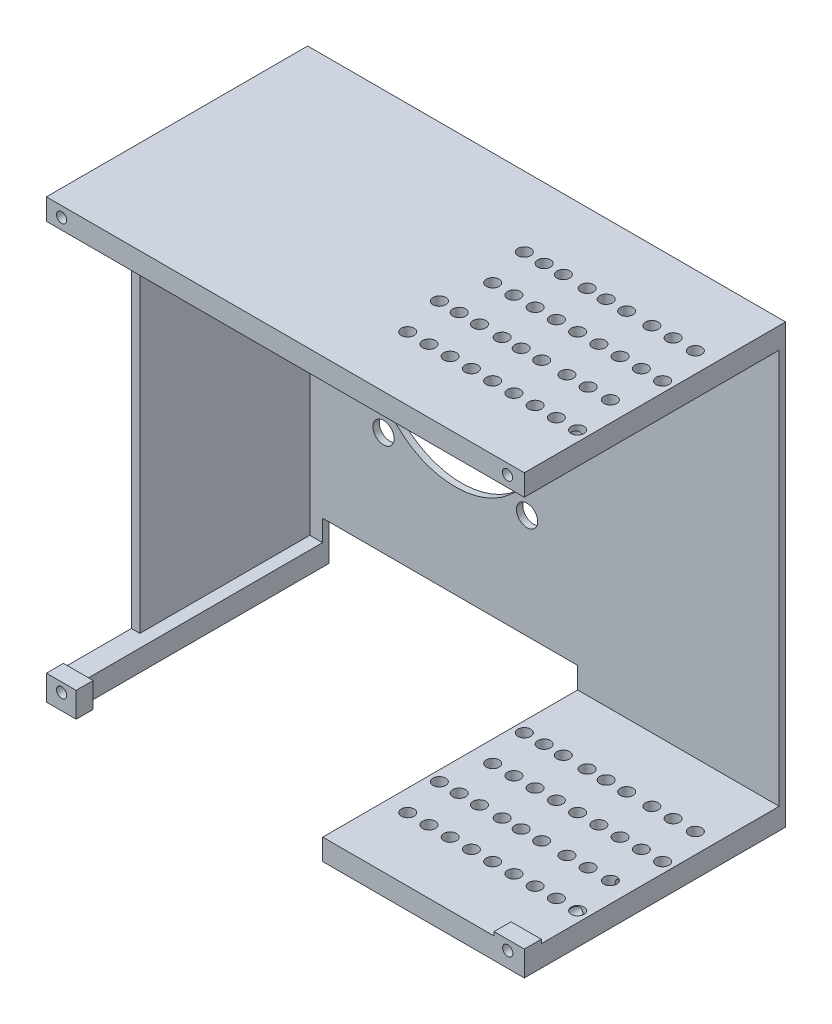
from build123d import *

# Parameters (mm, degrees)
SKETCH1_W           = 112.5
SKETCH1_H           = 103
BOSS_EXTRUDE1_DEPTH = 1.5
SKETCH2_W           = 112.5
SKETCH2_H           = 5
BOSS_EXTRUDE2_DEPTH = 60
SKETCH3_R           = 19.5
SKETCH3_R_2         = 2.5
CUT_EXTRUDE1_DEPTH  = 60
SKETCH4_W           = 112.5
SKETCH4_H           = 5
BOSS_EXTRUDE3_DEPTH = 60
SKETCH5_W           = 2
SKETCH5_H           = 93
BOSS_EXTRUDE4_DEPTH = 40
SKETCH6_W           = 60.047706822
SKETCH6_H           = 10
CUT_EXTRUDE2_DEPTH  = 70
SKETCH8_R           = 1.5
CUT_EXTRUDE4_DEPTH  = 103
SKETCH9_W           = 7
SKETCH9_H           = 5
BOSS_EXTRUDE5_DEPTH = 3
CUT_EXTRUDE5_START  = -61.5
SKETCH12_R          = 1.2
CUT_EXTRUDE5_DEPTH  = 30
SKETCH13_W          = 7.125955132
SKETCH13_H          = 5.899480028
SKETCH13_R          = 1.2
SKETCH13_W_2        = 7.001865144
BOSS_EXTRUDE7_DEPTH = 4


with BuildPart() as part:
    # Sketch1 → Boss-Extrude1 (new body)
    with BuildSketch(Plane.XY):
        with Locations((56.25, 51.5)):
            Rectangle(SKETCH1_W, SKETCH1_H)
    extrude(amount=BOSS_EXTRUDE1_DEPTH)

    # Sketch2 → Boss-Extrude2 (add)
    with BuildSketch(Plane.XY.offset(1.5)):
        with Locations((56.25, 100.5)):
            Rectangle(SKETCH2_W, SKETCH2_H)
    extrude(amount=BOSS_EXTRUDE2_DEPTH)

    # Sketch3 → Cut-Extrude1 (cut)
    with BuildSketch(Plane(origin=(0, 0, 0), x_dir=(-1, 0, 0), z_dir=(0, 0, -1))):
        with Locations((-36.25, 51.5)):
            Circle(SKETCH3_R)
        with Locations((-53.144291117, 68.394291117)):
            Circle(SKETCH3_R_2)
        with Locations((-19.355708883, 68.394291117)):
            Circle(SKETCH3_R_2)
        with Locations((-19.355708883, 34.605708883)):
            Circle(SKETCH3_R_2)
        with Locations((-53.144291117, 34.605708883)):
            Circle(SKETCH3_R_2)
    extrude(amount=-CUT_EXTRUDE1_DEPTH, mode=Mode.SUBTRACT)

    # Sketch4 → Boss-Extrude3 (add)
    with BuildSketch(Plane.XY.offset(1.5)):
        with Locations((56.25, 2.5)):
            Rectangle(SKETCH4_W, SKETCH4_H)
    extrude(amount=BOSS_EXTRUDE3_DEPTH)

    # Sketch5 → Boss-Extrude4 (add)
    with BuildSketch(Plane.XY.offset(1.5)):
        with Locations((1, 51.5)):
            Rectangle(SKETCH5_W, SKETCH5_H)
    extrude(amount=BOSS_EXTRUDE4_DEPTH)

    # Sketch6 → Cut-Extrude2 (cut)
    with BuildSketch(Plane(origin=(0, 0, 0), x_dir=(-1, 0, 0), z_dir=(0, 0, -1))):
        with Locations((-35.023853411, 5)):
            Rectangle(SKETCH6_W, SKETCH6_H)
    extrude(amount=-CUT_EXTRUDE2_DEPTH, mode=Mode.SUBTRACT)

    # Sketch8 → Cut-Extrude4 (cut)
    with BuildSketch(Plane.XZ):
        with Locations((110.047706822, 46.5)):
            Circle(SKETCH8_R)
        with Locations((105.047706822, 46.5)):
            Circle(SKETCH8_R)
        with Locations((100.047706822, 46.5)):
            Circle(SKETCH8_R)
        with Locations((95.047706822, 46.5)):
            Circle(SKETCH8_R)
        with Locations((90.047706822, 46.5)):
            Circle(SKETCH8_R)
        with Locations((85.047706822, 46.5)):
            Circle(SKETCH8_R)
        with Locations((80.047706822, 46.5)):
            Circle(SKETCH8_R)
        with Locations((75.047706822, 46.5)):
            Circle(SKETCH8_R)
        with Locations((70.047706822, 46.5)):
            Circle(SKETCH8_R)
        with Locations((107.760734586, 36.5)):
            Circle(SKETCH8_R)
        with Locations((102.526358176, 36.5)):
            Circle(SKETCH8_R)
        with Locations((97.524620718, 36.5)):
            Circle(SKETCH8_R)
        with Locations((91.592327453, 36.5)):
            Circle(SKETCH8_R)
        with Locations((86.765069208, 36.5)):
            Circle(SKETCH8_R)
        with Locations((82.286769391, 36.5)):
            Circle(SKETCH8_R)
        with Locations((76.936073505, 36.5)):
            Circle(SKETCH8_R)
        with Locations((72.166974998, 36.5)):
            Circle(SKETCH8_R)
        with Locations((67.5, 36.5)):
            Circle(SKETCH8_R)
        with Locations((110.047706822, 26.5)):
            Circle(SKETCH8_R)
        with Locations((105.047706822, 26.5)):
            Circle(SKETCH8_R)
        with Locations((100.047706822, 26.5)):
            Circle(SKETCH8_R)
        with Locations((95.047706822, 26.5)):
            Circle(SKETCH8_R)
        with Locations((90.047706822, 26.5)):
            Circle(SKETCH8_R)
        with Locations((85.047706822, 26.5)):
            Circle(SKETCH8_R)
        with Locations((80.047706822, 26.5)):
            Circle(SKETCH8_R)
        with Locations((75.047706822, 26.5)):
            Circle(SKETCH8_R)
        with Locations((70.047706822, 26.5)):
            Circle(SKETCH8_R)
        with Locations((107.760734586, 16.5)):
            Circle(SKETCH8_R)
        with Locations((102.526358176, 16.5)):
            Circle(SKETCH8_R)
        with Locations((97.524620718, 16.5)):
            Circle(SKETCH8_R)
        with Locations((91.592327453, 16.5)):
            Circle(SKETCH8_R)
        with Locations((86.765069208, 16.5)):
            Circle(SKETCH8_R)
        with Locations((82.286769391, 16.5)):
            Circle(SKETCH8_R)
        with Locations((76.68248017, 16.5)):
            Circle(SKETCH8_R)
        with Locations((72.166974998, 16.5)):
            Circle(SKETCH8_R)
        with Locations((67.5, 16.5)):
            Circle(SKETCH8_R)
    extrude(amount=-CUT_EXTRUDE4_DEPTH, mode=Mode.SUBTRACT)

    # Sketch9 → Boss-Extrude5 (add)
    with BuildSketch(Plane.XY.offset(61.5)):
        with Locations((3.5, 2.5)):
            Rectangle(SKETCH9_W, SKETCH9_H)
    extrude(amount=-BOSS_EXTRUDE5_DEPTH)

    # Sketch12 → Cut-Extrude5 (cut)
    with BuildSketch(Plane(origin=(0, 0, 0), x_dir=(-1, 0, 0), z_dir=(0, 0, -1)).offset(CUT_EXTRUDE5_START)):
        with Locations((-3.578936919, 3.760214318)):
            Circle(SKETCH12_R)
        with Locations((-108.599134944, 3.635123026)):
            Circle(SKETCH12_R)
        with Locations((-108.545365582, 100.601258517)):
            Circle(SKETCH12_R)
        with Locations((-3.578936919, 100.601258517)):
            Circle(SKETCH12_R)
    extrude(amount=CUT_EXTRUDE5_DEPTH, mode=Mode.SUBTRACT)

    # Sketch13 → Boss-Extrude7 (add)
    with BuildSketch(Plane.XY.offset(61.5)):
        with Locations((108.937022434, 2.949740014)):
            Rectangle(SKETCH13_W, SKETCH13_H)
        with Locations((108.599134944, 3.635123026)):
            Circle(SKETCH13_R, mode=Mode.SUBTRACT)
        with Locations((3.500932572, 2.949740014)):
            Rectangle(SKETCH13_W_2, SKETCH13_H)
        with Locations((3.578936919, 3.760214318)):
            Circle(SKETCH13_R, mode=Mode.SUBTRACT)
    extrude(amount=-BOSS_EXTRUDE7_DEPTH)


solid = part.part
